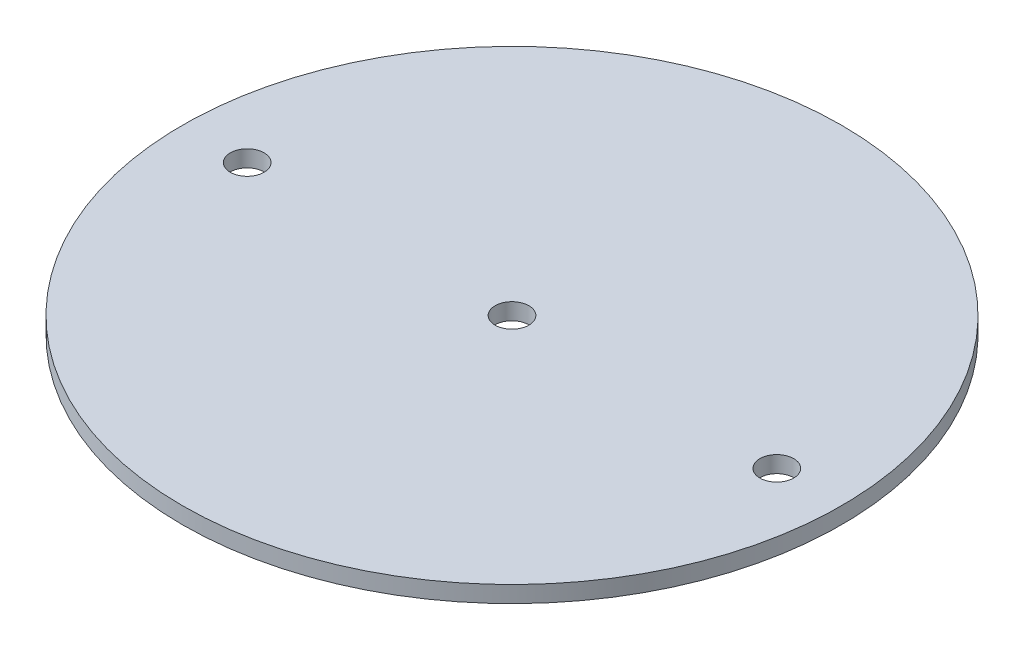
from build123d import *

# Parameters (mm, degrees)
SKETCH2_R           = 63.2206
SKETCH2_R_2         = 3.2385
BOSS_EXTRUDE1_DEPTH = 3.175


with BuildPart() as part:
    # Sketch2 → Boss-Extrude1 (new body)
    with BuildSketch(Plane(origin=(0, 0, 0), x_dir=(1, 0, 0), z_dir=(0, 1, 0))):
        Circle(SKETCH2_R)
        with Locations((-50.8, 0)):
            Circle(SKETCH2_R_2, mode=Mode.SUBTRACT)
        with Locations((50.8, 0)):
            Circle(SKETCH2_R_2, mode=Mode.SUBTRACT)
        Circle(SKETCH2_R_2, mode=Mode.SUBTRACT)
    extrude(amount=BOSS_EXTRUDE1_DEPTH)


solid = part.part
